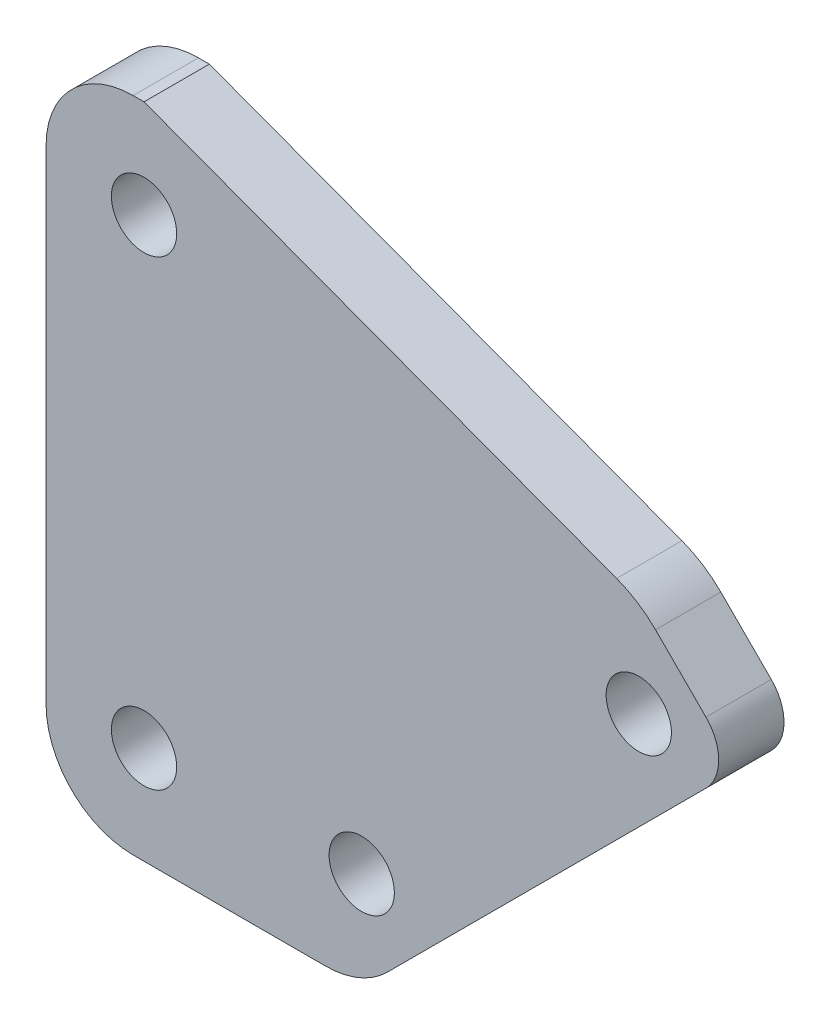
from build123d import *

# Parameters (mm, degrees)
SKETCH1_R           = 1.5
BOSS_EXTRUDE1_DEPTH = 3
FILLET1_R           = 2
FILLET3_R           = 5
FILLET5_R           = 4
FILLET6_R           = 4
FILLET7_R           = 4


with BuildPart() as part:
    # Sketch1 → Boss-Extrude1 (new body)
    with BuildSketch(Plane.XY):
        Polygon((0, 0), (14.5, 0), (19, 4.5), (31.727922061, 17.227922061), (27.227922061, 21.727922061), (4.5, 30.213203436), (0, 30.213203436), align=None)
        with Locations((4.5, 25.713203436)):
            Circle(SKETCH1_R, mode=Mode.SUBTRACT)
        with Locations((4.5, 4.5)):
            Circle(SKETCH1_R, mode=Mode.SUBTRACT)
        with Locations((14.5, 4.5)):
            Circle(SKETCH1_R, mode=Mode.SUBTRACT)
        with Locations((27.227922061, 17.227922061)):
            Circle(SKETCH1_R, mode=Mode.SUBTRACT)
    extrude(amount=BOSS_EXTRUDE1_DEPTH)

    # Fillet1
    fillet1_edges = [part.edges().sort_by_distance(p)[0] for p in [
        (31.727922061, 17.227922061, 1.5),
    ]]
    fillet(fillet1_edges, radius=FILLET1_R)

    # Fillet3
    fillet3_edges = [part.edges().sort_by_distance(p)[0] for p in [
        (27.227922061, 21.727922061, 1.5),
    ]]
    fillet(fillet3_edges, radius=FILLET3_R)

    # Fillet5
    fillet5_edges = [part.edges().sort_by_distance(p)[0] for p in [
        (0, 30.213203436, 1.5),
    ]]
    fillet(fillet5_edges, radius=FILLET5_R)

    # Fillet6
    fillet6_edges = [part.edges().sort_by_distance(p)[0] for p in [
        (0, 0, 1.5),
    ]]
    fillet(fillet6_edges, radius=FILLET6_R)

    # Fillet7
    fillet7_edges = [part.edges().sort_by_distance(p)[0] for p in [
        (14.5, 0, 1.5),
    ]]
    fillet(fillet7_edges, radius=FILLET7_R)


solid = part.part
